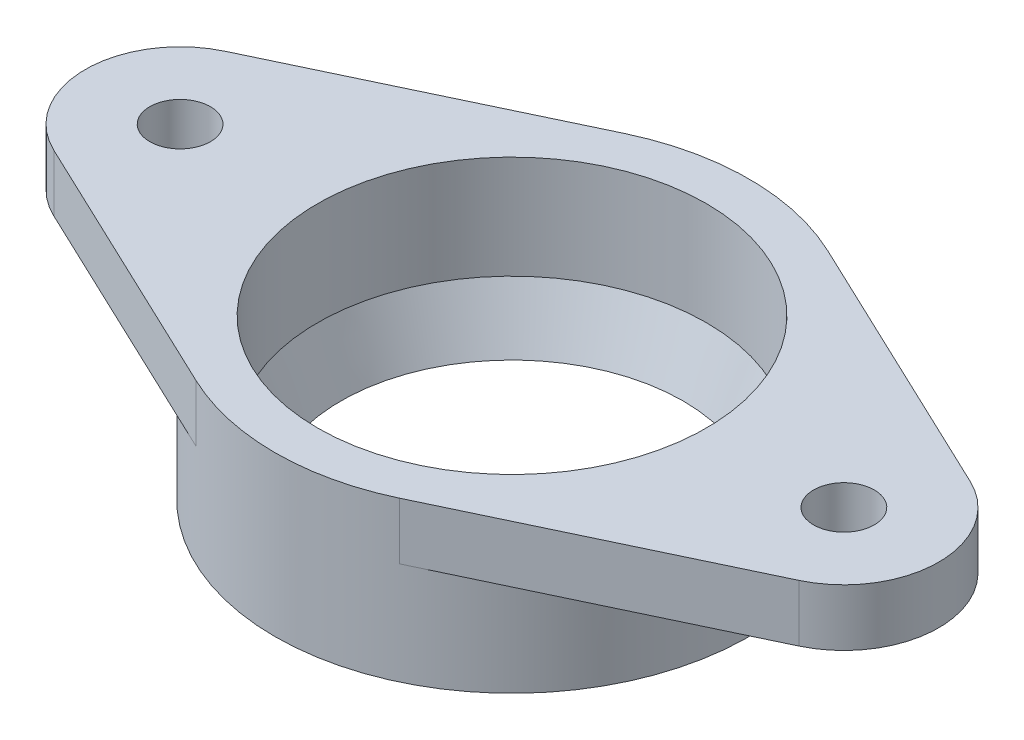
from build123d import *

# Parameters (mm, degrees)
SKETCH1_R               = 12.5
BOSS_EXTRUDE1_DEPTH     = 8.4
SKETCH2_R               = 10.25
CUT_EXTRUDE1_DEPTH      = 1
CUT_EXTRUDE1_DEPTH_BACK = 9.4
SKETCH4_R               = 1.6
BOSS_EXTRUDE2_DEPTH     = 3


with BuildPart() as part:
    # Sketch1 → Boss-Extrude1 (new body)
    with BuildSketch(Plane(origin=(0, 0, 0), x_dir=(1, 0, 0), z_dir=(0, 1, 0))):
        Circle(SKETCH1_R)
    extrude(amount=-BOSS_EXTRUDE1_DEPTH)

    # Sketch2 → Cut-Extrude1 (cut, two sides)
    with BuildSketch(Plane.XZ.offset(8.4)) as cut_extrude1_sk:
        Circle(SKETCH2_R)
    extrude(amount=CUT_EXTRUDE1_DEPTH, mode=Mode.SUBTRACT)
    extrude(cut_extrude1_sk.sketch, amount=-CUT_EXTRUDE1_DEPTH_BACK, mode=Mode.SUBTRACT)

    # Sketch3 → Revolve1 (revolve)
    with BuildSketch(Plane(origin=(0, 0, 0), x_dir=(0, 0, -1), z_dir=(1, 0, 0))):
        Polygon((9.023871751, -8.4), (12.5, 0), (12.5, -8.4), align=None)
    revolve(axis=Axis((0, -24.717, 0), (0, 1, 0)))

    # Sketch4 → Boss-Extrude2 (add)
    with BuildSketch(Plane(origin=(0, 0, 0), x_dir=(1, 0, 0), z_dir=(0, 1, 0))):
        with BuildLine():
            Line((-5.357142857, 11.293848786), (-19.642857143, 4.517539515))
            ThreePointArc((-19.642857143, 4.517539515), (-22.5, 0), (-19.642857143, -4.517539515))
            Line((-19.642857143, -4.517539515), (-5.357142857, -11.293848786))
            ThreePointArc((-5.357142857, -11.293848786), (-12.5, 0), (-5.357142857, 11.293848786))
        make_face()
        with Locations((-17.5, 0)):
            Circle(SKETCH4_R, mode=Mode.SUBTRACT)
        with BuildLine():
            Line((5.357142857, -11.293848786), (19.642857143, -4.517539515))
            ThreePointArc((19.642857143, -4.517539515), (22.5, 0), (19.642857143, 4.517539515))
            Line((19.642857143, 4.517539515), (5.357142857, 11.293848786))
            ThreePointArc((5.357142857, 11.293848786), (12.5, 0), (5.357142857, -11.293848786))
        make_face()
        with Locations((17.5, 0)):
            Circle(SKETCH4_R, mode=Mode.SUBTRACT)
    extrude(amount=-BOSS_EXTRUDE2_DEPTH)


solid = part.part
